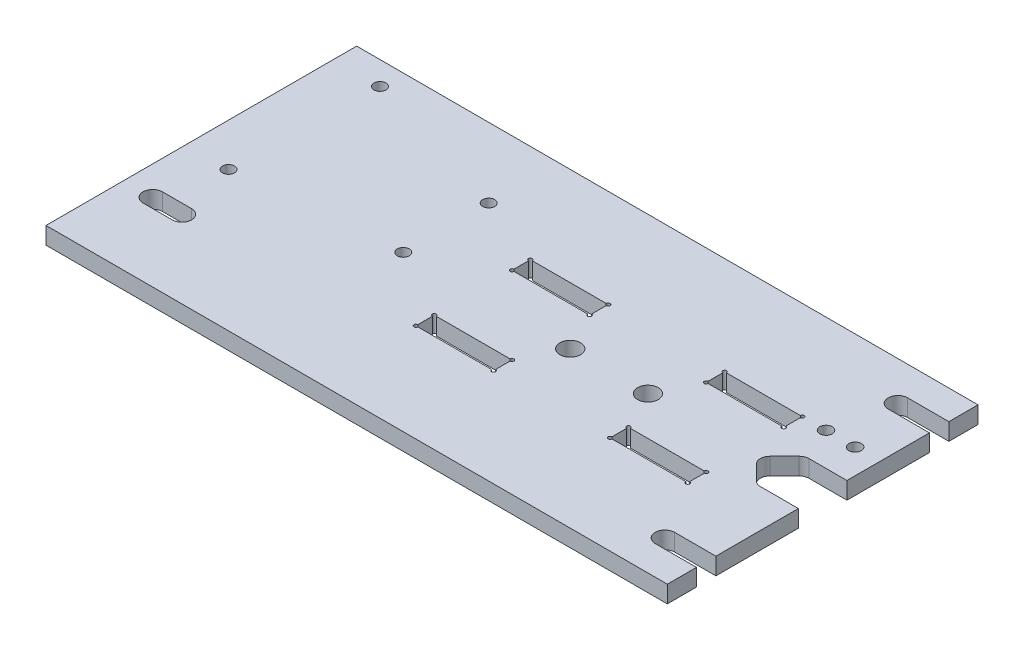
from build123d import *

# Parameters (mm, degrees)
BOSS_EXTRUDE1_DEPTH             = 5.588
F_1_4_CLEARANCE_HOLE1_D         = 6.35
F_1_4_CLEARANCE_HOLE1_DEPTH     = 5.588
CUT_EXTRUDE1_DEPTH              = 5.588
CUT_EXTRUDE2_REACH              = 7.588
F_4_CLEARANCE_HOLE1_D           = 3.937
F_4_CLEARANCE_HOLE1_DEPTH       = 5.588
CUT_EXTRUDE3_DEPTH              = 5.588
SKETCH15_R                      = 0.635
CUT_EXTRUDE5_DEPTH              = 5.588
MIRROR2_COPY_1_SKETCH_R         = 0.635
MIRROR2_COPY_1_DEPTH            = 5.588
F_10_CLEARANCE_HOLE1_D          = 6.7818
F_10_CLEARANCE_HOLE1_DEPTH      = 5.588
TAP_DRILL_FOR_4_HELICOIL1_D     = 4.064
TAP_DRILL_FOR_4_HELICOIL1_DEPTH = 6.35
TAP_DRILL_FOR_4_HELICOIL1_TIP   = 1.220948778
CUT_EXTRUDE4_REACH              = 7.588


with BuildPart() as part:
    # Sketch1 → Boss-Extrude1 (new body)
    with BuildSketch(Plane(origin=(0, 0, 0), x_dir=(1, 0, 0), z_dir=(0, 1, 0))):
        with BuildLine():
            Line((-101.6, 50.8), (101.6, 50.8))
            Line((101.6, 50.8), (101.6, 7.9375))
            Line((101.6, 7.9375), (89.172371939, 7.9375))
            ThreePointArc((89.172371939, 7.9375), (87.957352042, 7.695817516), (86.927307909, 7.00756403))
            Line((86.927307909, 7.00756403), (82.164807909, 2.24506403))
            ThreePointArc((82.164807909, 2.24506403), (81.234871939, 0), (82.164807909, -2.24506403))
            Line((82.164807909, -2.24506403), (86.927307909, -7.00756403))
            ThreePointArc((86.927307909, -7.00756403), (87.957352042, -7.695817516), (89.172371939, -7.9375))
            Line((89.172371939, -7.9375), (101.6, -7.9375))
            Line((101.6, -7.9375), (101.6, -50.8))
            Line((101.6, -50.8), (-101.6, -50.8))
            Line((-101.6, -50.8), (-101.6, 50.8))
        make_face()
    extrude(amount=BOSS_EXTRUDE1_DEPTH)

    # 1/4 Clearance Hole1
    with Locations(Plane(origin=(0, 5.588, 0), x_dir=(-1, 0, 0), z_dir=(0, 1, 0))):
        with Locations((-88.10625, 38.1), (-88.10625, -38.1), (88.9, 25.4)):
            Hole(F_1_4_CLEARANCE_HOLE1_D / 2, depth=F_1_4_CLEARANCE_HOLE1_DEPTH)

    # Sketch4 → Cut-Extrude1 (cut)
    with BuildSketch(Plane(origin=(0, 5.588, 0), x_dir=(1, 0, 0), z_dir=(0, 1, 0))):
        with BuildLine():
            Line((88.10625, 41.275), (101.6, 41.275))
            Line((101.6, 41.275), (101.6, 34.925))
            Line((101.6, 34.925), (88.10625, 34.925))
            ThreePointArc((88.10625, 34.925), (84.93125, 38.1), (88.10625, 41.275))
        make_face()
    cut_extrude1 = extrude(amount=-CUT_EXTRUDE1_DEPTH, mode=Mode.SUBTRACT)

    # Mirror1: Cut-Extrude1 across plane
    add(cut_extrude1.mirror(Plane.XY), mode=Mode.SUBTRACT)

    # Sketch5 → Cut-Extrude2 (cut, up to next)
    with BuildSketch(Plane(origin=(0, 5.588, 0), x_dir=(1, 0, 0), z_dir=(0, 1, 0)), mode=Mode.PRIVATE) as cut_extrude2_sk1:
        with BuildLine():
            Line((-92.075, -22.225), (-88.9, -22.225))
            ThreePointArc((-88.9, -22.225), (-85.725, -25.4), (-88.9, -28.575))
            Line((-88.9, -28.575), (-92.075, -28.575))
            ThreePointArc((-92.075, -28.575), (-95.25, -25.4), (-92.075, -22.225))
        make_face()
    cut_extrude2_tool1 = extrude(cut_extrude2_sk1.sketch, amount=-CUT_EXTRUDE2_REACH, mode=Mode.PRIVATE) & part.part
    add(cut_extrude2_tool1.solids().sort_by_distance((-90.4875, 5.588, 25.4))[0], mode=Mode.SUBTRACT)

    # #4 Clearance Hole1
    with Locations(Plane(origin=(0, 5.588, 0), x_dir=(-1, 0, 0), z_dir=(0, 1, 0))):
        with Locations((86.36, -43.18), (35.56, -27.94), (35.56, 0), (87.63, 5.08)):
            Hole(F_4_CLEARANCE_HOLE1_D / 2, depth=F_4_CLEARANCE_HOLE1_DEPTH)

    # Sketch9 → Cut-Extrude3 (cut)
    with BuildSketch(Plane(origin=(0, 5.588, 0), x_dir=(1, 0, 0), z_dir=(0, 1, 0))):
        Polygon((-6.0325, 18.7198), (6.0325, 18.7198), (6.35, 18.7198), (12.7, 18.7198), (12.7, 12.7), (6.35, 12.7), (6.0325, 12.7), (-6.0325, 12.7), (-6.35, 12.7), (-12.7, 12.7), (-12.7, 18.7198), (-6.35, 18.7198), align=None)
        Polygon((69.5325, 12.7), (57.4675, 12.7), (57.15, 12.7), (50.8, 12.7), (50.8, 18.7198), (57.15, 18.7198), (57.4675, 18.7198), (69.5325, 18.7198), (69.85, 18.7198), (76.2, 18.7198), (76.2, 12.7), (69.85, 12.7), align=None)
    cut_extrude3 = extrude(amount=-CUT_EXTRUDE3_DEPTH, mode=Mode.SUBTRACT)

    # Sketch15 → Cut-Extrude5 (cut)
    with BuildSketch(Plane(origin=(0, 5.588, 0), x_dir=(1, 0, 0), z_dir=(0, 1, 0))):
        with Locations((-12.7, 18.7198)):
            Circle(SKETCH15_R)
        with Locations((12.7, 18.7198)):
            Circle(SKETCH15_R)
        with Locations((12.7, 12.7)):
            Circle(SKETCH15_R)
        with Locations((-12.7, 12.7)):
            Circle(SKETCH15_R)
    cut_extrude5 = extrude(amount=-CUT_EXTRUDE5_DEPTH, mode=Mode.SUBTRACT)

    # Mirror3: Cut-Extrude5 across plane
    add(cut_extrude5.mirror(Plane.ZY.offset(-31.75)), mode=Mode.SUBTRACT)

    # Mirror2: Cut-Extrude3, Cut-Extrude5 across plane
    add(cut_extrude3.mirror(Plane.XY), mode=Mode.SUBTRACT)
    add(cut_extrude5.mirror(Plane.XY), mode=Mode.SUBTRACT)

    # Mirror2 copy 1 sketch → Mirror2 copy 1 (cut)
    with BuildSketch(Plane(origin=(63.5, 5.588, 0), x_dir=(-1, 0, 0), z_dir=(0, 1, 0))):
        with Locations((-12.7, 18.7198)):
            Circle(MIRROR2_COPY_1_SKETCH_R)
        with Locations((12.7, 18.7198)):
            Circle(MIRROR2_COPY_1_SKETCH_R)
        with Locations((12.7, 12.7)):
            Circle(MIRROR2_COPY_1_SKETCH_R)
        with Locations((-12.7, 12.7)):
            Circle(MIRROR2_COPY_1_SKETCH_R)
    extrude(amount=-MIRROR2_COPY_1_DEPTH, mode=Mode.SUBTRACT)

    # #10 Clearance Hole1
    with Locations(Plane(origin=(0, 5.588, 0), x_dir=(-1, 0, 0), z_dir=(0, 1, 0))):
        with Locations((-19.05, 0), (-44.45, 0)):
            Hole(F_10_CLEARANCE_HOLE1_D / 2, depth=F_10_CLEARANCE_HOLE1_DEPTH)

    # Tap Drill for #4 Helicoil1
    with Locations(Plane(origin=(0, 5.588, 0), x_dir=(1, 0, 0), z_dir=(0, 1, 0))):
        with Locations((93.4847, 18.7325), (83.9597, 18.7325)):
            Hole(TAP_DRILL_FOR_4_HELICOIL1_D / 2, depth=TAP_DRILL_FOR_4_HELICOIL1_DEPTH)
            with Locations((0, 0, -(TAP_DRILL_FOR_4_HELICOIL1_DEPTH + TAP_DRILL_FOR_4_HELICOIL1_TIP / 2))):  # 118° drill point
                Cone(0, TAP_DRILL_FOR_4_HELICOIL1_D / 2, TAP_DRILL_FOR_4_HELICOIL1_TIP, mode=Mode.SUBTRACT)

    # Sketch14 → Cut-Extrude4 (cut, up to next)
    with BuildSketch(Plane(origin=(0, 5.588, 0), x_dir=(1, 0, 0), z_dir=(0, 1, 0)), mode=Mode.PRIVATE) as cut_extrude4_sk1:
        with BuildLine():
            Line((-88.9, -22.225), (-82.55, -22.225))
            ThreePointArc((-82.55, -22.225), (-79.375, -25.4), (-82.55, -28.575))
            Line((-82.55, -28.575), (-88.9, -28.575))
            ThreePointArc((-88.9, -28.575), (-85.725, -25.4), (-88.9, -22.225))
        make_face()
    cut_extrude4_tool1 = extrude(cut_extrude4_sk1.sketch, amount=-CUT_EXTRUDE4_REACH, mode=Mode.PRIVATE) & part.part
    add(cut_extrude4_tool1.solids().sort_by_distance((-83.231361, 5.588, 25.4))[0], mode=Mode.SUBTRACT)


solid = part.part
